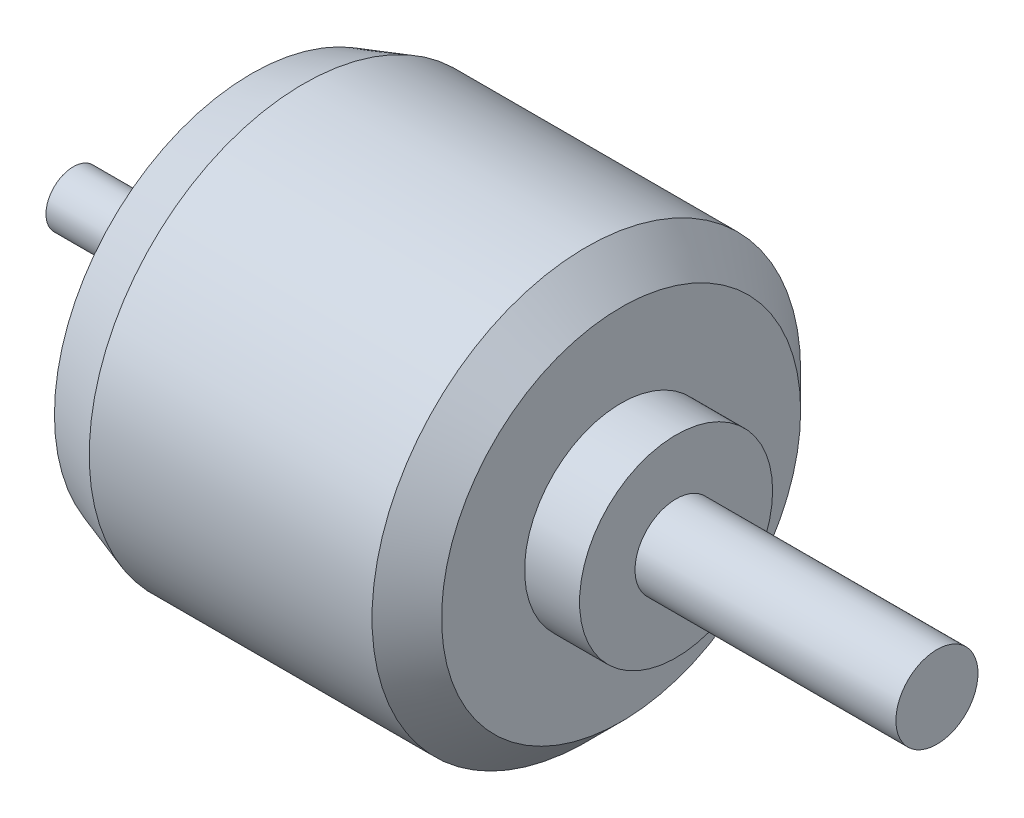
from build123d import *

# Parameters (mm, degrees)
SKETCH2_R           = 4
BOSS_EXTRUDE1_DEPTH = 26
SKETCH3_R           = 31.3
BOSS_EXTRUDE2_DEPTH = 54
SKETCH4_R           = 2
CUT_EXTRUDE1_DEPTH  = 8
CHAMFER1_SIZE       = 2.54
CHAMFER1_SIZE2      = 7.62
CHAMFER2_SIZE       = 5.08
SKETCH5_R           = 14.097
BOSS_EXTRUDE3_DEPTH = 8.0264
SKETCH6_R           = 5.9944
BOSS_EXTRUDE4_DEPTH = 38.1


with BuildPart() as part:
    # Sketch2 → Boss-Extrude1 (new body)
    with BuildSketch(Plane(origin=(0, 0, 0), x_dir=(0, 0, -1), z_dir=(1, 0, 0))):
        Circle(SKETCH2_R)
    extrude(amount=BOSS_EXTRUDE1_DEPTH)

    # Sketch3 → Boss-Extrude2 (add)
    with BuildSketch(Plane(origin=(26, 0, 0), x_dir=(0, 0, -1), z_dir=(1, 0, 0))):
        Circle(SKETCH3_R)
    extrude(amount=BOSS_EXTRUDE2_DEPTH)

    # Sketch4 → Cut-Extrude1 (cut)
    with BuildSketch(Plane.ZY.offset(-26)):
        with Locations((15, 0)):
            Circle(SKETCH4_R)
        with Locations((0, -22)):
            Circle(SKETCH4_R)
        with Locations((0, -15)):
            Circle(SKETCH4_R)
        with Locations((-15, 0)):
            Circle(SKETCH4_R)
        with Locations((0, 15)):
            Circle(SKETCH4_R)
        with Locations((0, 22)):
            Circle(SKETCH4_R)
        with Locations((22, 0)):
            Circle(SKETCH4_R)
        with Locations((-22, 0)):
            Circle(SKETCH4_R)
    extrude(amount=-CUT_EXTRUDE1_DEPTH, mode=Mode.SUBTRACT)

    # Chamfer1
    chamfer1_edges = [part.edges().sort_by_distance(p)[0] for p in [
        (26, 0, 31.3),
    ]]
    chamfer1_side = [part.faces().sort_by_distance(p)[0] for p in [
        (26, 0, 30.41470231),
    ]]
    chamfer(chamfer1_edges, length=CHAMFER1_SIZE, length2=CHAMFER1_SIZE2, reference=chamfer1_side[0])

    # Chamfer2
    chamfer2_edges = [part.edges().sort_by_distance(p)[0] for p in [
        (80, 0, 31.3),
    ]]
    chamfer(chamfer2_edges, length=CHAMFER2_SIZE)

    # Sketch5 → Boss-Extrude3 (add)
    with BuildSketch(Plane(origin=(80, 0, 0), x_dir=(0, 0, -1), z_dir=(1, 0, 0))):
        Circle(SKETCH5_R)
    extrude(amount=BOSS_EXTRUDE3_DEPTH)

    # Sketch6 → Boss-Extrude4 (add)
    with BuildSketch(Plane(origin=(88.0264, 0, 0), x_dir=(0, 0, -1), z_dir=(1, 0, 0))):
        Circle(SKETCH6_R)
    extrude(amount=BOSS_EXTRUDE4_DEPTH)


solid = part.part
